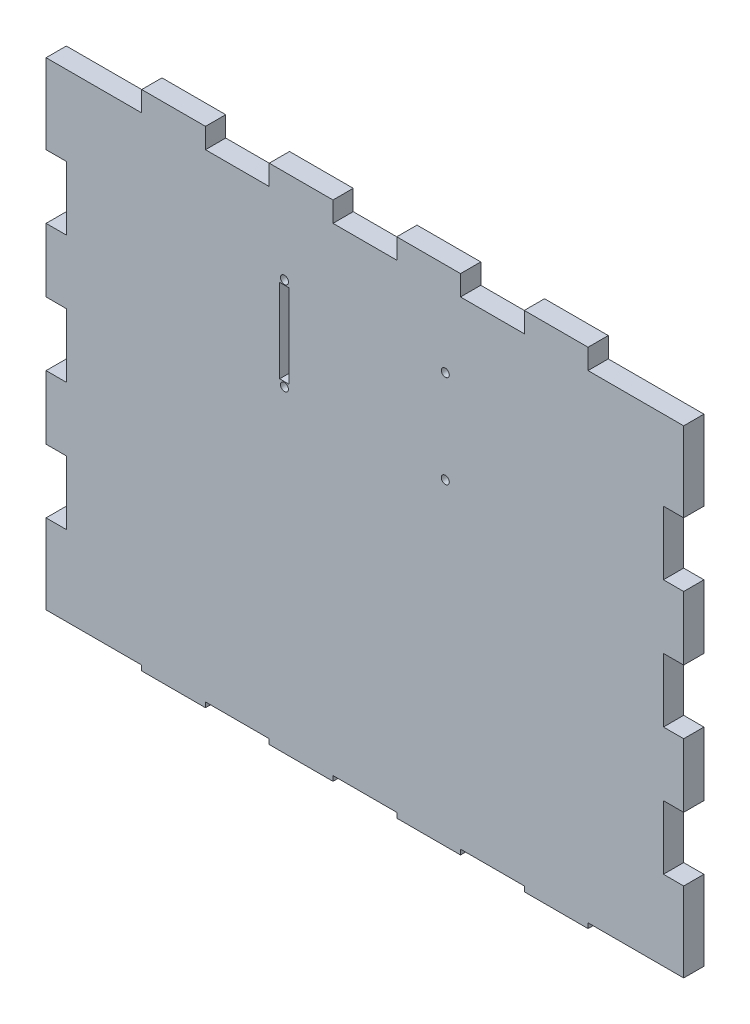
from build123d import *

# Parameters (mm, degrees)
SKETCH1_R           = 1.25
SKETCH1_W           = 3
SKETCH1_H           = 26.2
BOSS_EXTRUDE4_DEPTH = 6.35


with BuildPart() as part:
    # Sketch1 → Boss-Extrude4 (new body)
    with BuildSketch(Plane.XY):
        Polygon((0, 25), (0, 0), (30, 0), (30, -1.5875), (50, -1.5875), (50, 0), (70, 0), (70, -1.5875), (90, -1.5875), (90, 0), (110, 0), (110, -1.5875), (130, -1.5875), (130, 0), (150, 0), (150, -1.5875), (170, -1.5875), (170, 0), (200, 0), (200, 25), (193.65, 25), (193.65, 45), (200, 45), (200, 65), (193.65, 65), (193.65, 85), (200, 85), (200, 105), (193.65, 105), (193.65, 125), (200, 125), (200, 150), (170, 150), (170, 156.35), (150, 156.35), (150, 150), (130, 150), (130, 156.35), (110, 156.35), (110, 150), (90, 150), (90, 156.35), (70, 156.35), (70, 150), (50, 150), (50, 156.35), (30, 156.35), (30, 150), (0, 150), (0, 125), (6.35, 125), (6.35, 105), (0, 105), (0, 85), (6.35, 85), (6.35, 65), (0, 65), (0, 45), (6.35, 45), (6.35, 25), align=None)
        with Locations((74.769797365, 97.95)):
            Circle(SKETCH1_R, mode=Mode.SUBTRACT)
        with Locations((74.769797365, 112.5)):
            Rectangle(SKETCH1_W, SKETCH1_H, mode=Mode.SUBTRACT)
        with Locations((74.769797365, 127.05)):
            Circle(SKETCH1_R, mode=Mode.SUBTRACT)
        with Locations((125.230202635, 97.95)):
            Circle(SKETCH1_R, mode=Mode.SUBTRACT)
        with Locations((125.230202635, 127.05)):
            Circle(SKETCH1_R, mode=Mode.SUBTRACT)
    extrude(amount=BOSS_EXTRUDE4_DEPTH)


solid = part.part
